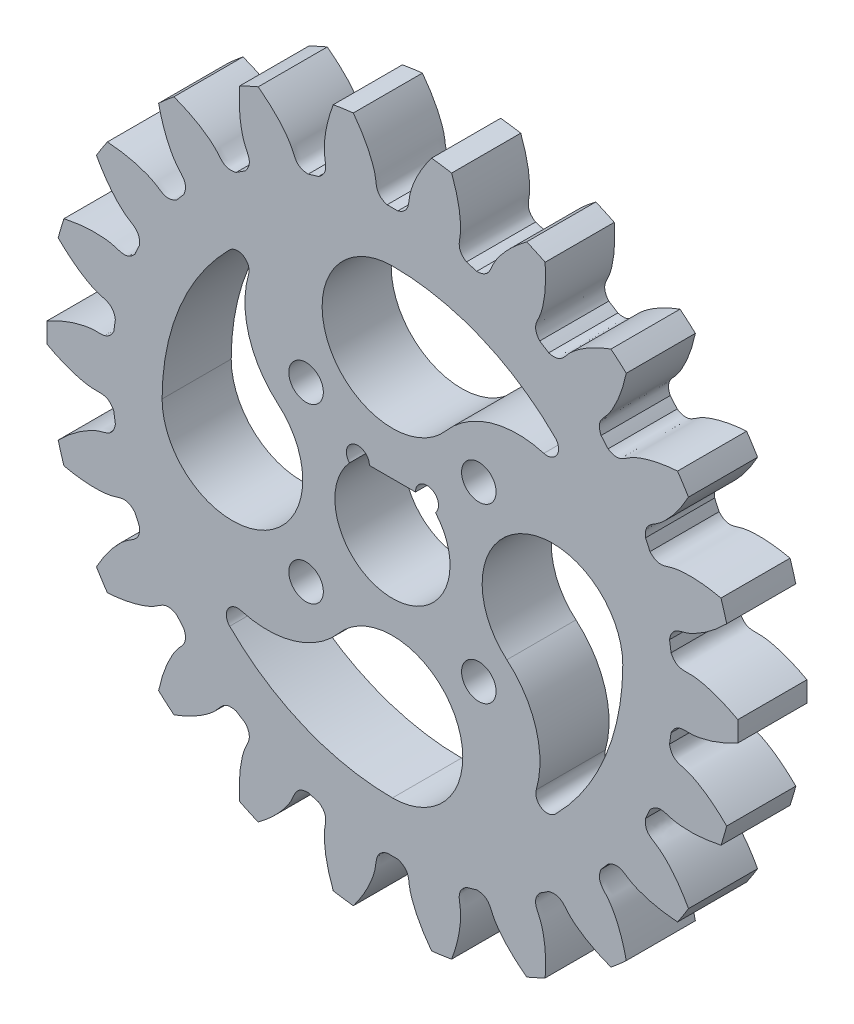
from build123d import *

# Parameters (mm, degrees)
SKETCH_1_R               = 30
SKETCH_1_R_2             = 1.5
EXTRUDE_1_DEPTH          = 6
CUT_EXTRUDE_1_DEPTH      = 43.848570571
PATTERN_CIRCULAR_1_COUNT = 22
SKETCH_3_R               = 1
CUT_EXTRUDE_2_DEPTH      = 43.713783174


with BuildPart() as part:
    # 草图1 → 凸台-拉伸1 (new body)
    with BuildSketch(Plane.XY):
        Circle(SKETCH_1_R)
        with Locations((-7.5, 7.5)):
            Circle(SKETCH_1_R_2, mode=Mode.SUBTRACT)
        with Locations((7.5, 7.5)):
            Circle(SKETCH_1_R_2, mode=Mode.SUBTRACT)
        with Locations((7.5, -7.5)):
            Circle(SKETCH_1_R_2, mode=Mode.SUBTRACT)
        with Locations((-7.5, -7.5)):
            Circle(SKETCH_1_R_2, mode=Mode.SUBTRACT)
        with BuildLine():
            Line((-3, 4), (3, 4))
            ThreePointArc((3, 4), (0, -5), (-3, 4))
        make_face(mode=Mode.SUBTRACT)
    extrude(amount=EXTRUDE_1_DEPTH)

    # 草图2 → 切除-拉伸1 (cut, through all)
    with BuildSketch(Plane.XY):
        with BuildLine():
            ThreePointArc((0.464163579, 24.370580157), (0, 24.375), (-0.464163579, 24.370580157))
            add(Edge.make_bspline(
                [(-0.464163579, 24.370580157), (-1.470396765, 24.690466072), (-1.37086816, 25.379436739), (-1.498960117, 26.053925976), (-1.514902949, 26.129797257), (-1.534692242, 26.215405531), (-1.558709302, 26.310626078), (-1.587349834, 26.415319133), (-1.620999856, 26.529334154), (-1.660042927, 26.652508597), (-1.704857477, 26.784668445), (-1.755817225, 26.9256282), (-1.81329065, 27.075191045), (-1.877640758, 27.233148973), (-1.949224754, 27.39928293), (-2.028393764, 27.573362962), (-2.115492528, 27.755148376), (-2.210859123, 27.944387905), (-2.314824671, 28.140819876), (-2.427713062, 28.344172393), (-2.549840678, 28.55416352), (-2.681516121, 28.770501477), (-2.823039948, 28.992884838), (-2.974704407, 29.221002737), (-3.136793184, 29.454535083), (-3.309581149, 29.693152778), (-3.49333411, 29.936517944), (-3.688308577, 30.184284154), (-3.894751521, 30.43609667), (-4.11290015, 30.691592691), (-4.342981684, 30.950401595), (-4.585213139, 31.212145203), (-4.839801118, 31.476438036), (-5.106941604, 31.742887582), (-5.386819764, 32.011094568), (-5.679609759, 32.280653234), (-5.985474556, 32.551151622), (-6.304565771, 32.822171852), (-6.637023407, 33.093290427), (-7.103720317, 33.458588846), (-7.466114287, 33.724920257), (-7.713896996, 33.89967032)],
                knots=[0, 0, 0, 0, 0.157021319, 0.162530984, 0.168888289, 0.176093235, 0.184145822, 0.19304605, 0.202793918, 0.213389427, 0.224832576, 0.237123367, 0.250261798, 0.264247869, 0.279081582, 0.294762935, 0.311291928, 0.328668563, 0.346892838, 0.365964754, 0.38588431, 0.406651508, 0.428266346, 0.450728824, 0.474038944, 0.498196704, 0.523202104, 0.549055146, 0.575755828, 0.603304151, 0.631700114, 0.660943719, 0.691034964, 0.721973849, 0.753760376, 0.786394543, 0.819876351, 0.854205799, 0.889382888, 0.925407618, 1, 1, 1, 1], degree=3))
            ThreePointArc((-7.713896996, 33.89967032), (0, 34.76624591), (7.713896996, 33.89967032))
            add(Edge.make_bspline(
                [(0.464163579, 24.370580157), (1.470396765, 24.690466072), (1.37086816, 25.379436739), (1.498960117, 26.053925976), (1.514902949, 26.129797257), (1.534692242, 26.215405531), (1.558709302, 26.310626078), (1.587349834, 26.415319133), (1.620999856, 26.529334154), (1.660042927, 26.652508597), (1.704857477, 26.784668445), (1.755817225, 26.9256282), (1.81329065, 27.075191045), (1.877640758, 27.233148973), (1.949224754, 27.39928293), (2.028393764, 27.573362962), (2.115492528, 27.755148376), (2.210859123, 27.944387905), (2.314824671, 28.140819876), (2.427713062, 28.344172393), (2.549840678, 28.55416352), (2.681516121, 28.770501477), (2.823039948, 28.992884838), (2.974704407, 29.221002737), (3.136793184, 29.454535083), (3.309581149, 29.693152778), (3.49333411, 29.936517944), (3.688308577, 30.184284154), (3.894751521, 30.43609667), (4.11290015, 30.691592691), (4.342981684, 30.950401595), (4.585213139, 31.212145203), (4.839801118, 31.476438036), (5.106941604, 31.742887582), (5.386819764, 32.011094568), (5.679609759, 32.280653234), (5.985474556, 32.551151622), (6.304565771, 32.822171852), (6.637023407, 33.093290427), (7.103720317, 33.458588846), (7.466114287, 33.724920257), (7.713896996, 33.89967032)],
                knots=[0, 0, 0, 0, 0.157021319, 0.162530984, 0.168888289, 0.176093235, 0.184145822, 0.19304605, 0.202793918, 0.213389427, 0.224832576, 0.237123367, 0.250261798, 0.264247869, 0.279081582, 0.294762935, 0.311291928, 0.328668563, 0.346892838, 0.365964754, 0.38588431, 0.406651508, 0.428266346, 0.450728824, 0.474038944, 0.498196704, 0.523202104, 0.549055146, 0.575755828, 0.603304151, 0.631700114, 0.660943719, 0.691034964, 0.721973849, 0.753760376, 0.786394543, 0.819876351, 0.854205799, 0.889382888, 0.925407618, 1, 1, 1, 1], degree=3))
        make_face()
    cut_extrude_1 = extrude(amount=CUT_EXTRUDE_1_DEPTH, mode=Mode.SUBTRACT)

    # 阵列(圆周)1: 切除-拉伸1 ×22 about axis
    pattern_circular_1_axis = Axis((0, 0, 6), (0, 0, -1))
    for i in range(1, PATTERN_CIRCULAR_1_COUNT):
        add(cut_extrude_1.rotate(pattern_circular_1_axis, i * 360 / PATTERN_CIRCULAR_1_COUNT), mode=Mode.SUBTRACT)

    # 草图3 → 切除-拉伸2 (cut, through all)
    with BuildSketch(Plane.XY.offset(6)):
        with Locations((-3, 4)):
            Circle(SKETCH_3_R)
        with Locations((3, 4)):
            Circle(SKETCH_3_R)
        with BuildLine():
            ThreePointArc((0, 20), (-5.543790473, 11.335558243), (4.646341463, 9.932926829))
            ThreePointArc((4.646341463, 9.932926829), (8.520217961, 12.461446995), (13.146204753, 12.485520796))
            ThreePointArc((13.146204753, 12.485520796), (14.285153682, 12.938130954), (14.130359404, 14.153902046))
            ThreePointArc((14.130359404, 14.153902046), (7.645977998, 18.480774347), (0, 20))
        make_face()
        with BuildLine():
            ThreePointArc((20, 0), (11.335558243, 5.543790473), (9.932926829, -4.646341463))
            ThreePointArc((9.932926829, -4.646341463), (12.461446995, -8.520217961), (12.485520796, -13.146204753))
            ThreePointArc((12.485520796, -13.146204753), (12.938130954, -14.285153682), (14.153902046, -14.130359404))
            ThreePointArc((14.153902046, -14.130359404), (18.480774347, -7.645977998), (20, 0))
        make_face()
        with BuildLine():
            ThreePointArc((0, -20), (5.543790473, -11.335558243), (-4.646341463, -9.932926829))
            ThreePointArc((-4.646341463, -9.932926829), (-8.520217961, -12.461446995), (-13.146204753, -12.485520796))
            ThreePointArc((-13.146204753, -12.485520796), (-14.285153682, -12.938130954), (-14.130359404, -14.153902046))
            ThreePointArc((-14.130359404, -14.153902046), (-7.645977998, -18.480774347), (0, -20))
        make_face()
        with BuildLine():
            ThreePointArc((-20, 0), (-11.335558243, -5.543790473), (-9.932926829, 4.646341463))
            ThreePointArc((-9.932926829, 4.646341463), (-12.461446995, 8.520217961), (-12.485520796, 13.146204753))
            ThreePointArc((-12.485520796, 13.146204753), (-12.938130954, 14.285153682), (-14.153902046, 14.130359404))
            ThreePointArc((-14.153902046, 14.130359404), (-18.480774347, 7.645977998), (-20, 0))
        make_face()
    extrude(amount=-CUT_EXTRUDE_2_DEPTH, mode=Mode.SUBTRACT)


solid = part.part
